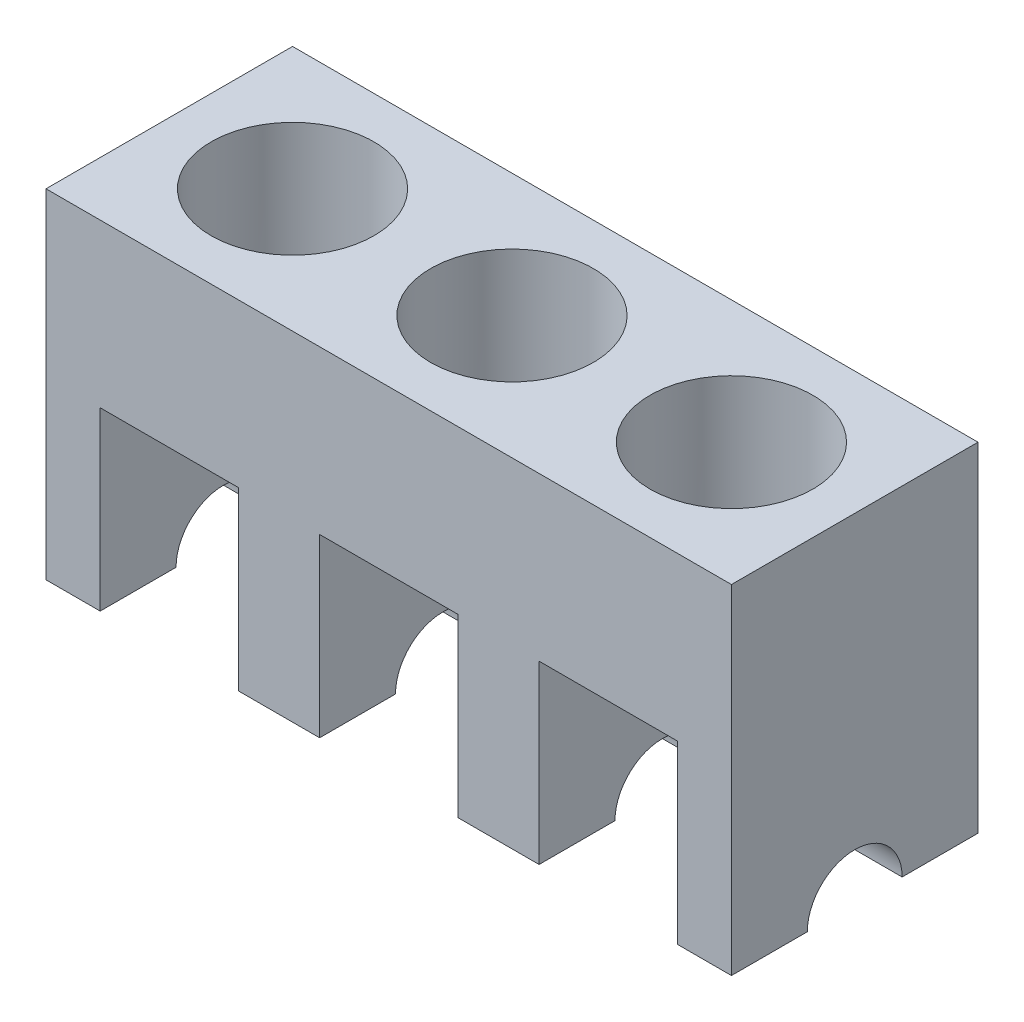
from build123d import *

# Parameters (mm, degrees)
SKETCH1_W           = 253
SKETCH1_H           = 91
BOSS_EXTRUDE1_DEPTH = 125
SKETCH2_W           = 51
SKETCH2_H           = 65
CUT_EXTRUDE1_DEPTH  = 92
SKETCH3_R           = 30.05
CUT_EXTRUDE2_DEPTH  = 81
SKETCH4_R           = 17.5
CUT_EXTRUDE3_DEPTH  = 254


with BuildPart() as part:
    # Sketch1 → Boss-Extrude1 (new body)
    with BuildSketch(Plane(origin=(0, 0, 0), x_dir=(1, 0, 0), z_dir=(0, 1, 0))):
        with Locations((126.5, -45.5)):
            Rectangle(SKETCH1_W, SKETCH1_H)
    extrude(amount=BOSS_EXTRUDE1_DEPTH)

    # Sketch2 → Cut-Extrude1 (cut, through all)
    with BuildSketch(Plane.XY.offset(91)):
        with Locations((45.5, 32.5)):
            Rectangle(SKETCH2_W, SKETCH2_H)
        with Locations((126.5, 32.5)):
            Rectangle(SKETCH2_W, SKETCH2_H)
        with Locations((207.5, 32.5)):
            Rectangle(SKETCH2_W, SKETCH2_H)
    extrude(amount=-CUT_EXTRUDE1_DEPTH, mode=Mode.SUBTRACT)

    # Sketch3 → Cut-Extrude2 (cut)
    with BuildSketch(Plane(origin=(0, 125, 0), x_dir=(1, 0, 0), z_dir=(0, 1, 0))):
        with Locations((45.5, -45.5)):
            Circle(SKETCH3_R)
        with Locations((126.5, -45.5)):
            Circle(SKETCH3_R)
        with Locations((207.5, -45.5)):
            Circle(SKETCH3_R)
    extrude(amount=-CUT_EXTRUDE2_DEPTH, mode=Mode.SUBTRACT)

    # Sketch4 → Cut-Extrude3 (cut, through all)
    with BuildSketch(Plane(origin=(253, 0, 0), x_dir=(0, 0, -1), z_dir=(1, 0, 0))):
        with Locations((-45.5, 0)):
            Circle(SKETCH4_R)
    extrude(amount=-CUT_EXTRUDE3_DEPTH, mode=Mode.SUBTRACT)


solid = part.part
